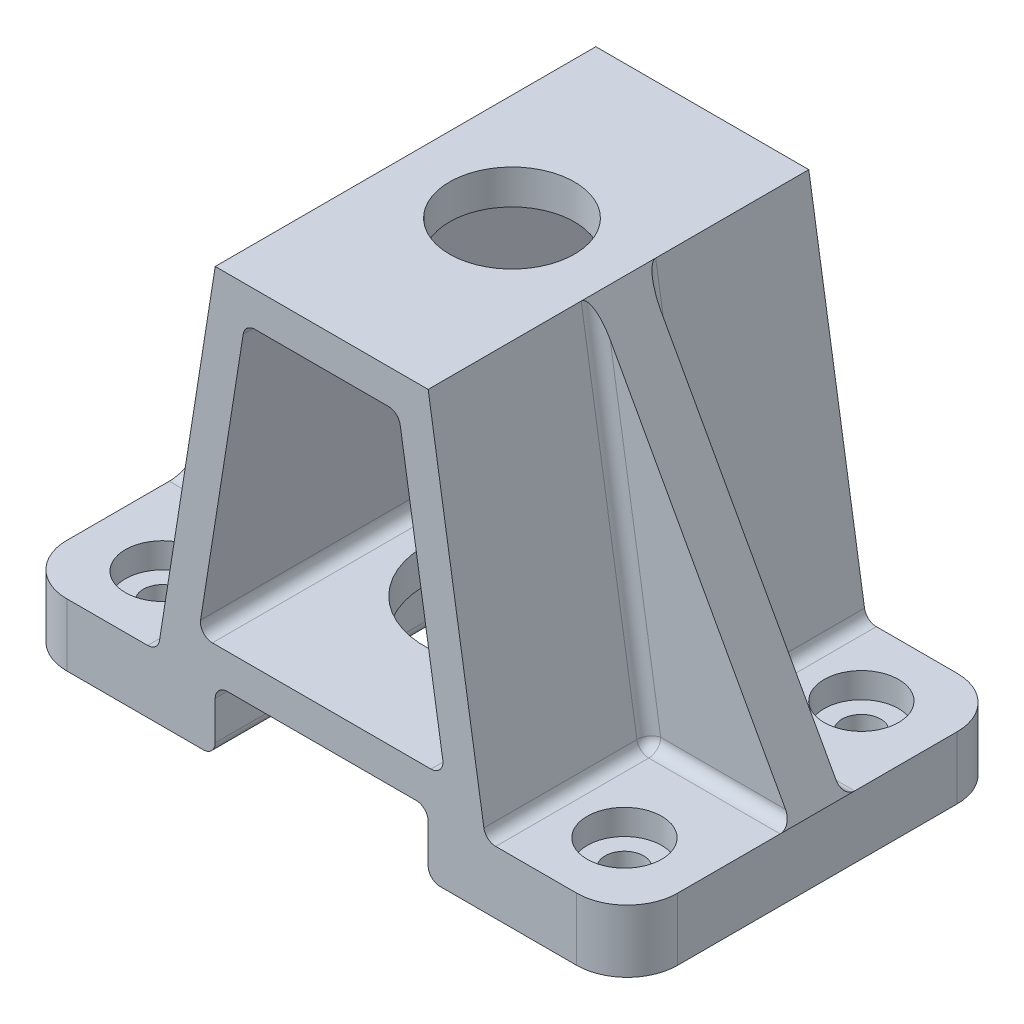
from build123d import *

# Parameters (mm, degrees)
SKETCH1_W            = 116.586
SKETCH1_H            = 72.644
EXTRUDE1_DEPTH       = 11.938
SKETCH2_R            = 9.517718459
CUT_EXTRUDE1_DEPTH   = 89.365734061
SKETCH5_W            = 40.64
SKETCH5_H            = 72.644
EXTRUDE3_DEPTH       = 69.088
EXTRUDE3_DRAFT       = 9
SKETCH6_W            = 40.64
SKETCH6_H            = 72.644
CUT_EXTRUDE3_DEPTH   = 11.938
SKETCH7_W            = 69.622985634
SKETCH7_H            = 14.548045231
CUT_EXTRUDE4_DEPTH   = 117.249686156
SKETCH8_W            = 84.138542923
SKETCH8_H            = 16.028207861
CUT_EXTRUDE5_DEPTH   = 117.249686156
SHELL1_T             = -6.604
CUT_EXTRUDE6_REACH   = 113.531
SKETCH9_R            = 16.637
CUT_EXTRUDE7_REACH   = 121.295
SKETCH10_R           = 11.938
SKETCH14_R           = 9.517718459
EXTRUDE5_DEPTH       = 11.938
SKETCH15_R           = 3.683
CUT_EXTRUDE10_DEPTH  = 120.294592451
SKETCH16_R           = 7.112
CUT_EXTRUDE11_DEPTH  = 4.826
LPATTERN2_COUNT      = 2
LPATTERN2_PITCH      = 45.212
LPATTERN2_COUNT_DIR2 = 2
LPATTERN2_PITCH_DIR2 = 88.138
FILLET1_R            = 9.652
FILLET2_R            = 2.286
FILLET3_R            = 2.286
RIB1_REACH           = 118.817
SKETCH21_WALL_W      = 314.469849536
SKETCH21_WALL_H      = 9.652
RIB2_REACH           = 118.817
SKETCH22_WALL_W      = 314.469849536
SKETCH22_WALL_H      = 9.652
FILLET4_R            = 2.286
FILLET5_R            = 2.286


with BuildPart() as part:
    # Sketch1 → Extrude1 (new body)
    with BuildSketch(Plane(origin=(0, 0, 0), x_dir=(1, 0, 0), z_dir=(0, 1, 0))):
        with Locations((-17.610350746, 7.320507463)):
            Rectangle(SKETCH1_W, SKETCH1_H)
    extrude(amount=EXTRUDE1_DEPTH)

    # Sketch2 → Cut-Extrude1 (cut, through all)
    with BuildSketch(Plane(origin=(0, 11.938, 0), x_dir=(-1, 0, 0), z_dir=(0, 1, 0))):
        with Locations(Location((-26.458649254, 15.285492537, 0), (0, 0, 90))):
            Circle(SKETCH2_R)
    extrude(amount=-CUT_EXTRUDE1_DEPTH, mode=Mode.SUBTRACT)


with BuildPart() as extrude3_tool:
    # Sketch5 → Extrude3 (with draft: the straight prism first)
    with BuildSketch(Plane(origin=(0, 81.026, 0), x_dir=(-1, 0, 0), z_dir=(0, 1, 0))):
        with Locations((17.610350746, -7.320507463)):
            Rectangle(SKETCH5_W, SKETCH5_H)
    extrude(amount=-EXTRUDE3_DEPTH)
    # Extrude3: the draft: its side faces are tilted about the plane it starts from
    extrude3_sides = [extrude3_tool.faces().sort_by_distance(p)[0] for p in [
        (-37.930350746, 46.482, -7.320507463),
        (-17.610350746, 46.482, 29.001492537),
        (2.709649254, 46.482, -7.320507463),
        (-17.610350746, 46.482, -43.642507463),
    ]]
    draft(extrude3_sides, Plane(origin=(0, 81.026, 0), x_dir=(-1, 0, 0), z_dir=(0, 1, 0)), EXTRUDE3_DRAFT)


with BuildPart() as part_1:
    add(part.part)

    # Extrude3: add extrude3_tool
    add(extrude3_tool.part)

    # Sketch6 → Cut-Extrude3 (cut)
    with BuildSketch(Plane.XZ):
        with Locations((-17.610350746, -7.320507463)):
            Rectangle(SKETCH6_W, SKETCH6_H)
    extrude(amount=-CUT_EXTRUDE3_DEPTH, mode=Mode.SUBTRACT)

    # Sketch7 → Cut-Extrude4 (cut, through all)
    with BuildSketch(Plane.XZ.offset(-11.938)):
        with Locations((-17.718126266, 36.275515152)):
            Rectangle(SKETCH7_W, SKETCH7_H)
    extrude(amount=-CUT_EXTRUDE4_DEPTH, mode=Mode.SUBTRACT)

    # Sketch8 → Cut-Extrude5 (cut, through all)
    with BuildSketch(Plane.XZ.offset(-11.938)):
        with Locations((-14.253759939, -51.656611394)):
            Rectangle(SKETCH8_W, SKETCH8_H)
    extrude(amount=-CUT_EXTRUDE5_DEPTH, mode=Mode.SUBTRACT)

    # Shell1
    shell1_openings = [part_1.faces().sort_by_distance(p)[0] for p in [
        (-17.610350746, 36.31822783, -43.642507463),
        (-17.610350746, 36.31822783, 29.001492537),
    ]]
    offset(amount=SHELL1_T, openings=shell1_openings, kind=Kind.INTERSECTION)

    # Sketch9 → Cut-Extrude6 (cut, up to next)
    with BuildSketch(Plane.XZ.offset(-11.938), mode=Mode.PRIVATE) as cut_extrude6_sk1:
        with Locations(Location((-17.610350746, -7.320507463, 0), (0, 0, 270))):
            Circle(SKETCH9_R)
    cut_extrude6_tool1 = extrude(cut_extrude6_sk1.sketch, amount=-CUT_EXTRUDE6_REACH, mode=Mode.PRIVATE) & part_1.part
    add(cut_extrude6_tool1.solids().sort_by_distance((-17.610351, 11.938, -7.320507))[0], mode=Mode.SUBTRACT)

    # Sketch10 → Cut-Extrude7 (cut, up to next)
    with BuildSketch(Plane(origin=(0, 81.026, 0), x_dir=(-1, 0, 0), z_dir=(0, 1, 0)), mode=Mode.PRIVATE) as cut_extrude7_sk1:
        with Locations(Location((17.610350746, -7.320507463, 0), (0, 0, 90))):
            Circle(SKETCH10_R)
    cut_extrude7_tool1 = extrude(cut_extrude7_sk1.sketch, amount=-CUT_EXTRUDE7_REACH, mode=Mode.PRIVATE) & part_1.part
    add(cut_extrude7_tool1.solids().sort_by_distance((-17.610351, 81.026, -7.320507))[0], mode=Mode.SUBTRACT)

    # Sketch14 → Extrude5 (add)
    with BuildSketch(Plane.XZ):
        with Locations((26.458649254, 15.285492537)):
            Circle(SKETCH14_R)
    extrude(amount=-EXTRUDE5_DEPTH)

    # Sketch15 → Cut-Extrude10 (cut, through all)
    with BuildSketch(Plane.XZ):
        with Locations(Location((26.458649254, 15.285492537, 0), (0, 0, 270))):
            Circle(SKETCH15_R)
    cut_extrude10 = extrude(amount=-CUT_EXTRUDE10_DEPTH, mode=Mode.SUBTRACT)

    # Sketch16 → Cut-Extrude11 (cut)
    with BuildSketch(Plane(origin=(0, 11.938, 0), x_dir=(-1, 0, 0), z_dir=(0, 1, 0))):
        with Locations(Location((-26.458649254, 15.285492537, 0), (0, 0, 90))):
            Circle(SKETCH16_R)
    cut_extrude11 = extrude(amount=-CUT_EXTRUDE11_DEPTH, mode=Mode.SUBTRACT)

    # LPattern2: Cut-Extrude10, Cut-Extrude11 2 × 2
    with Locations(*[(-j * LPATTERN2_PITCH_DIR2, 0, -i * LPATTERN2_PITCH) for i in range(LPATTERN2_COUNT) for j in range(LPATTERN2_COUNT_DIR2) if (i, j) != (0, 0)]):
        add(cut_extrude10, mode=Mode.SUBTRACT)
        add(cut_extrude11, mode=Mode.SUBTRACT)

    # Fillet1
    fillet1_edges = [part_1.edges().sort_by_distance(p)[0] for p in [
        (-75.903350746, 5.969, -43.642507463),
        (40.682649254, 5.969, -43.642507463),
        (40.682649254, 5.969, 29.001492537),
        (-75.903350746, 5.969, 29.001492537),
    ]]
    fillet(fillet1_edges, radius=FILLET1_R)

    # Fillet2
    fillet2_edges = [part_1.edges().sort_by_distance(p)[0] for p in [
        (5.919822932, 18.542, -7.320507463),
        (-41.140524425, 18.542, -7.320507463),
        (-32.290001899, 74.422, -7.320507463),
        (-2.930699593, 74.422, -7.320507463),
    ]]
    fillet(fillet2_edges, radius=FILLET2_R)

    # Fillet3
    fillet3_edges = [part_1.edges().sort_by_distance(p)[0] for p in [
        (-37.930350746, 11.938, -7.320507463),
        (2.709649254, 11.938, -7.320507463),
    ]]
    fillet(fillet3_edges, radius=FILLET3_R)

    # Sketch21 wall → Rib1 (add, up to next)
    with BuildSketch(Plane(origin=(21.696149254, 46.482, -7.3152), x_dir=(0.481671369181, -0.876351922524, 0), z_dir=(0.876351922524, 0.481671369181, 0)), mode=Mode.PRIVATE) as rib1_sk1:
        Rectangle(SKETCH21_WALL_W, SKETCH21_WALL_H)
    rib1_tool1 = extrude(rib1_sk1.sketch, amount=-RIB1_REACH, mode=Mode.PRIVATE) - part_1.part
    add(rib1_tool1.solids().sort_by_distance((21.696149254, 46.482, -7.3152))[0])

    # Sketch22 wall → Rib2 (add, up to next)
    with BuildSketch(Plane(origin=(-56.916850746, 46.482, -7.3152), x_dir=(-0.481671369181, -0.876351922524, 0), z_dir=(0.876351922524, -0.481671369181, 0)), mode=Mode.PRIVATE) as rib2_sk1:
        Rectangle(SKETCH22_WALL_W, SKETCH22_WALL_H)
    rib2_tool1 = extrude(rib2_sk1.sketch, amount=RIB2_REACH, mode=Mode.PRIVATE) - part_1.part
    add(rib2_tool1.solids().sort_by_distance((-56.916850746, 46.482, -7.3152))[0])

    # Fillet4
    fillet4_edges = [part_1.edges().sort_by_distance(p)[0] for p in [
        (13.652113467, 11.938, 13.256146269),
        (-48.872814959, 11.938, -27.891853731),
        (13.652113467, 11.938, -27.891853731),
        (8.18088136, 46.482, -12.1412),
        (27.16738136, 11.938, -12.1412),
        (8.18088136, 46.482, -2.4892),
        (27.16738136, 11.938, -2.4892),
        (-48.872814959, 11.938, 13.256146269),
        (-62.388082853, 11.938, -2.4892),
        (-43.401582853, 46.482, -2.4892),
        (-62.388082853, 11.938, -12.1412),
        (-43.401582853, 46.482, -12.1412),
    ]]
    fillet(fillet4_edges, radius=FILLET4_R)

    # Fillet5
    fillet5_edges = [part_1.edges().sort_by_distance(p)[0] for p in [
        (-37.930350746, 0, -7.320507463),
        (2.709649254, 0, -7.320507463),
    ]]
    fillet(fillet5_edges, radius=FILLET5_R)


solid = part_1.part
